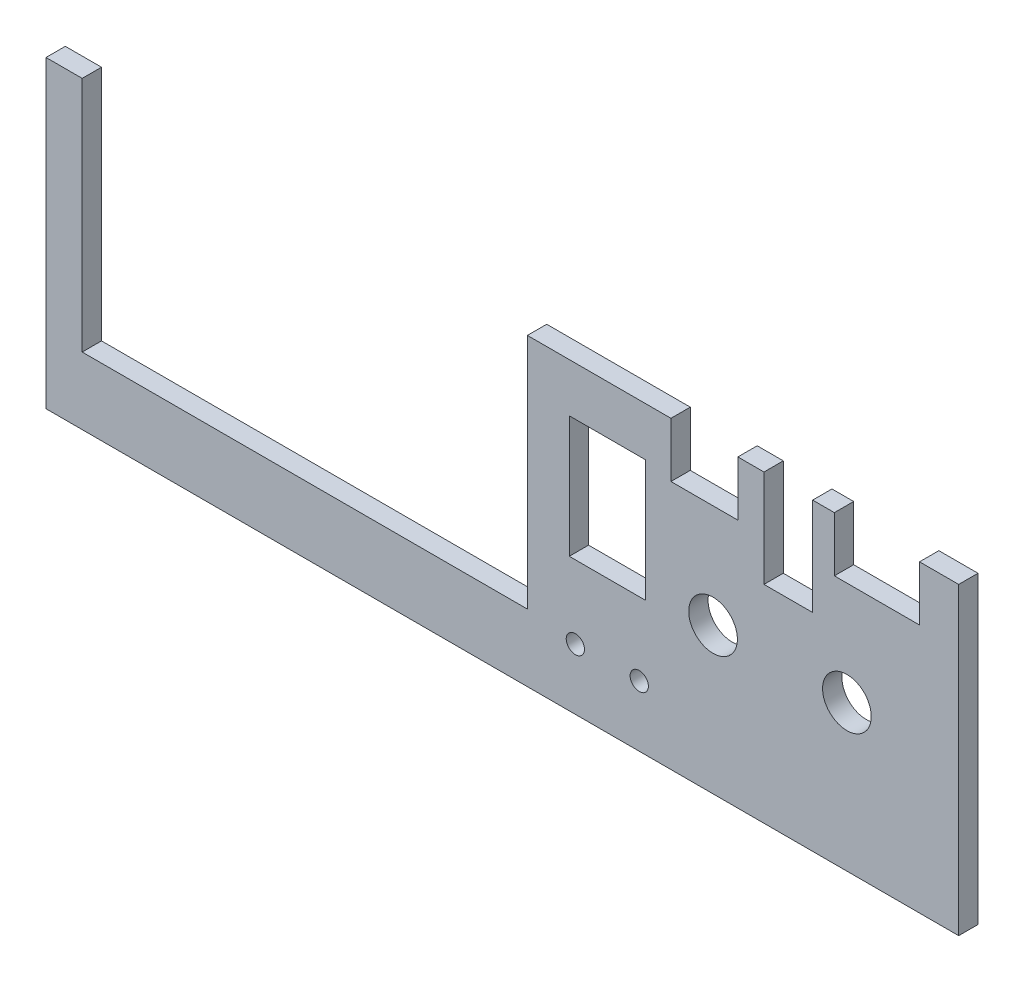
from build123d import *

# Parameters (mm, degrees)
SKETCH2_R           = 1.5
SKETCH2_R_2         = 4
SKETCH2_W           = 12.5
SKETCH2_H           = 20
BOSS_EXTRUDE1_DEPTH = 3.175
BOSS_EXTRUDE2_DEPTH = 3.175


with BuildPart() as part:
    # Sketch2 → Boss-Extrude1 (new body)
    with BuildSketch(Plane.XY):
        Polygon((-71.75862069, 50), (-71.75862069, 2), (74.24137931, 2), (74.24137931, 50), (69.808349218, 50), (69.808349218, 41), (55.808349218, 41), (55.808349218, 50), (52.24137931, 50), (52.24137931, 34), (44.24137931, 34), (44.24137931, 50), (39.953145567, 50), (39.953145567, 41), (28.953145567, 41), (28.953145567, 50), (5.35837424, 50), (5.35837424, 11.04586532), (-67.810407441, 11.04586532), (-67.810407441, 50), align=None)
        with Locations((23.74137931, 10)):
            Circle(SKETCH2_R, mode=Mode.SUBTRACT)
        with Locations((13.24137931, 10)):
            Circle(SKETCH2_R, mode=Mode.SUBTRACT)
        with Locations((57.871281099, 24)):
            Circle(SKETCH2_R_2, mode=Mode.SUBTRACT)
        with Locations((35.871281099, 24)):
            Circle(SKETCH2_R_2, mode=Mode.SUBTRACT)
        with Locations((18.49137931, 32)):
            Rectangle(SKETCH2_W, SKETCH2_H, mode=Mode.SUBTRACT)
    extrude(amount=BOSS_EXTRUDE1_DEPTH)

    # Sketch3 → Boss-Extrude2 (add)
    with BuildSketch(Plane(origin=(0, 0, 0), x_dir=(-1, 0, 0), z_dir=(0, 0, -1))):
        Polygon((-74.24137931, 50), (-76.24137931, 50), (-76.24137931, 0), (73.75862069, 0), (73.75862069, 50), (71.75862069, 50), (71.75862069, 2), (-74.24137931, 2), align=None)
    extrude(amount=-BOSS_EXTRUDE2_DEPTH)


solid = part.part
